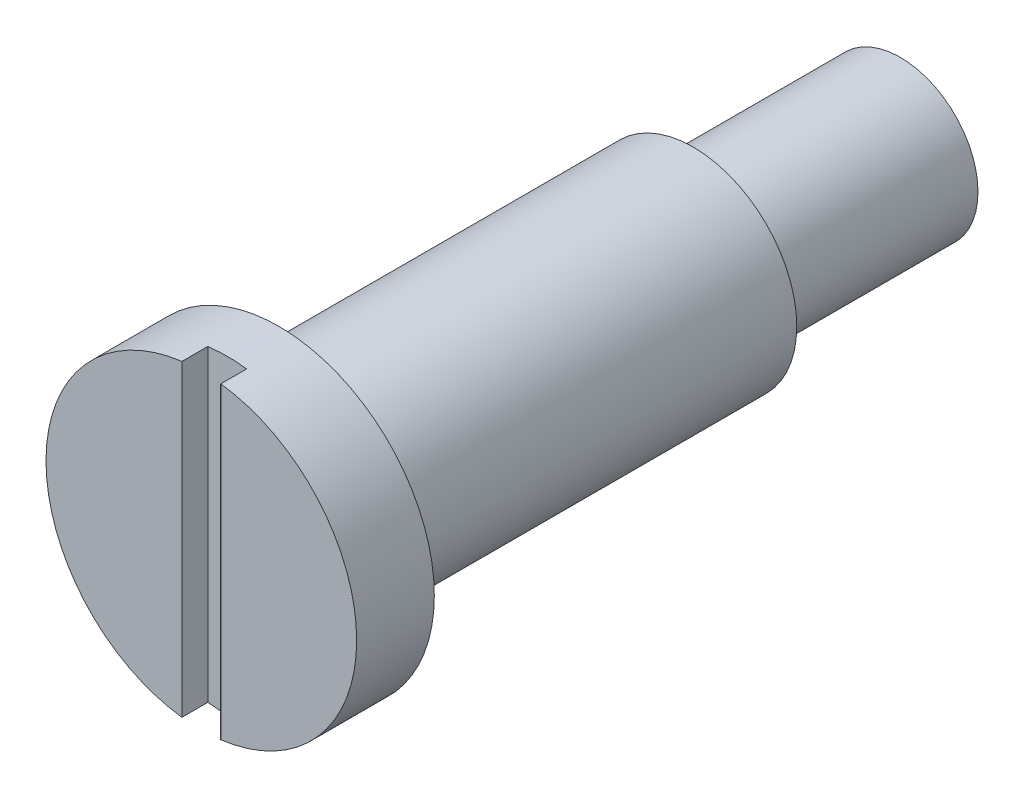
from build123d import *

# Parameters (mm, degrees)
SKETCH_3_W          = 1.5
SKETCH_3_H          = 12
CUT_EXTRUDE_1_DEPTH = 1


with BuildPart() as part:
    # 草图2 → 旋转1 (revolve)
    with BuildSketch(Plane(origin=(0, 0, 0), x_dir=(0, 0, -1), z_dir=(1, 0, 0))):
        Polygon((0, 0), (0, 6), (3, 6), (3, 4), (19, 4), (19, 3), (27, 3), (27, 0), align=None)
    revolve(axis=Axis((0, 0, 0), (0, 0, -1)))

    # 草图3 → 切除-拉伸1 (cut)
    with BuildSketch(Plane.XY):
        Rectangle(SKETCH_3_W, SKETCH_3_H)
    extrude(amount=-CUT_EXTRUDE_1_DEPTH, mode=Mode.SUBTRACT)


solid = part.part
